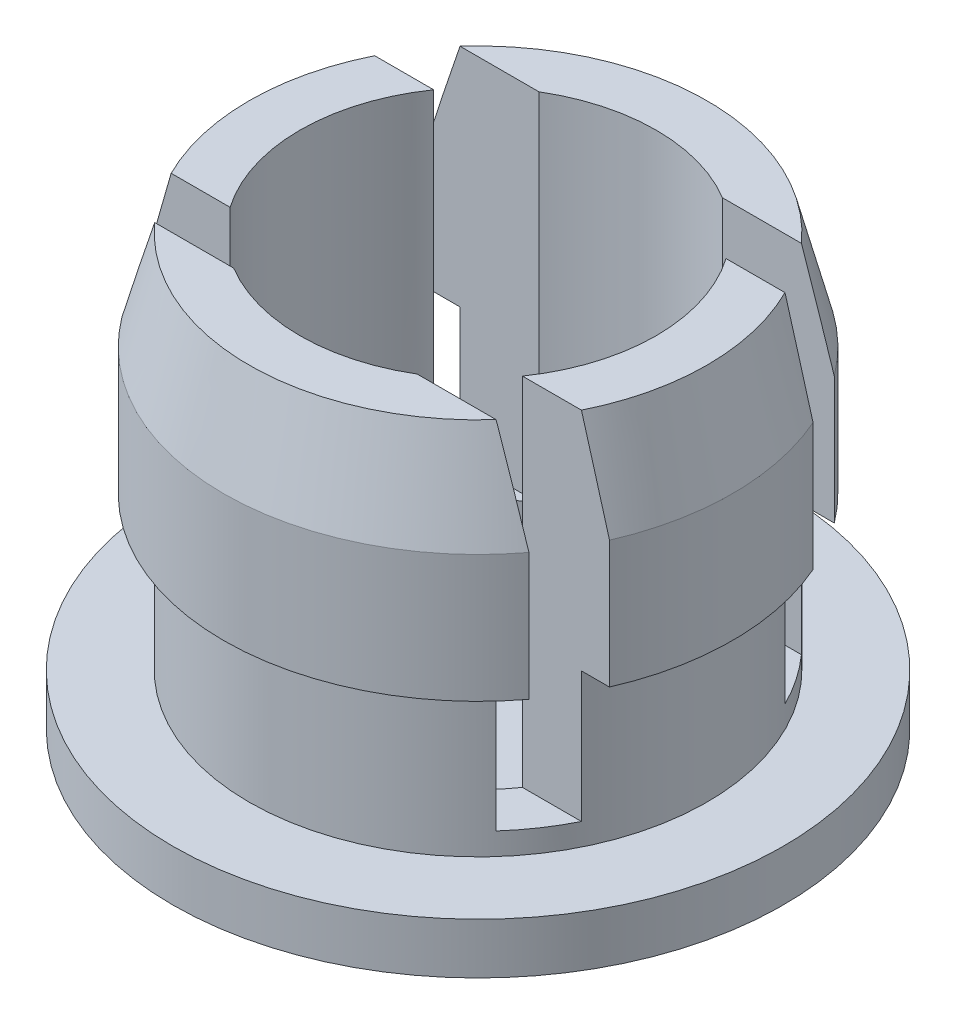
from build123d import *

# Parameters (mm, degrees)
CROQUIS2_W            = 26
CROQUIS2_H            = 2
CORTAR_EXTRUIR1_DEPTH = 14


with BuildPart() as part:
    # Croquis1 → Revolución1 (revolve)
    with BuildSketch(Plane.XY):
        Polygon((-78.782252338, -15.637996222), (-90.782252338, -15.637996222), (-90.782252338, -13.637996222), (-87.782252338, -13.637996222), (-87.782252338, -7.637996222), (-88.782252338, -7.637996222), (-88.782252338, -2.637996222), (-87.782252338, 1.235955759), (-85.782252338, 1.235955759), (-85.782252338, -13.637996222), (-78.782252338, -13.637996222), align=None)
    revolve(axis=Axis((-78.782252338, -13.637996222, 0), (0, -1, 0)))

    # Croquis2 → Cortar-Extruir1 (cut)
    with BuildSketch(Plane(origin=(0, 1.235955759, 0), x_dir=(1, 0, 0), z_dir=(0, 1, 0))):
        with Locations((-78.782252338, -5)):
            Rectangle(CROQUIS2_W, CROQUIS2_H)
        with Locations((-78.782252338, 5)):
            Rectangle(CROQUIS2_W, CROQUIS2_H)
    extrude(amount=-CORTAR_EXTRUIR1_DEPTH, mode=Mode.SUBTRACT)


solid = part.part
